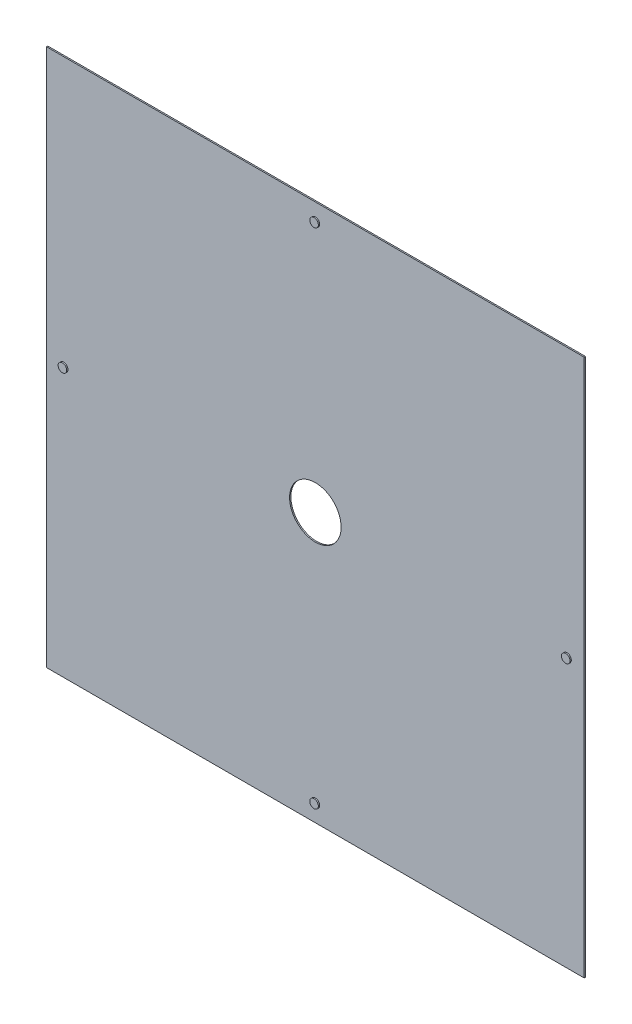
from build123d import *

# Parameters (mm, degrees)
SKETCH2_W           = 626
SKETCH2_H           = 626
SKETCH2_R           = 30
BOSS_EXTRUDE1_DEPTH = 1.5
SKETCH3_R           = 5
BOSS_EXTRUDE2_DEPTH = 1.5


with BuildPart() as part:
    # Sketch2 → Boss-Extrude1 (new body)
    with BuildSketch(Plane.XY):
        Rectangle(SKETCH2_W, SKETCH2_H)
        Circle(SKETCH2_R, mode=Mode.SUBTRACT)
    extrude(amount=BOSS_EXTRUDE1_DEPTH)

    # Sketch3 → Boss-Extrude2 (add)
    with BuildSketch(Plane.XY.offset(1.5)):
        with Locations((0, 293)):
            Circle(SKETCH3_R)
        with Locations((-293, 0)):
            Circle(SKETCH3_R)
        with Locations((0, -293)):
            Circle(SKETCH3_R)
        with Locations((293, 0)):
            Circle(SKETCH3_R)
    extrude(amount=BOSS_EXTRUDE2_DEPTH)


solid = part.part
